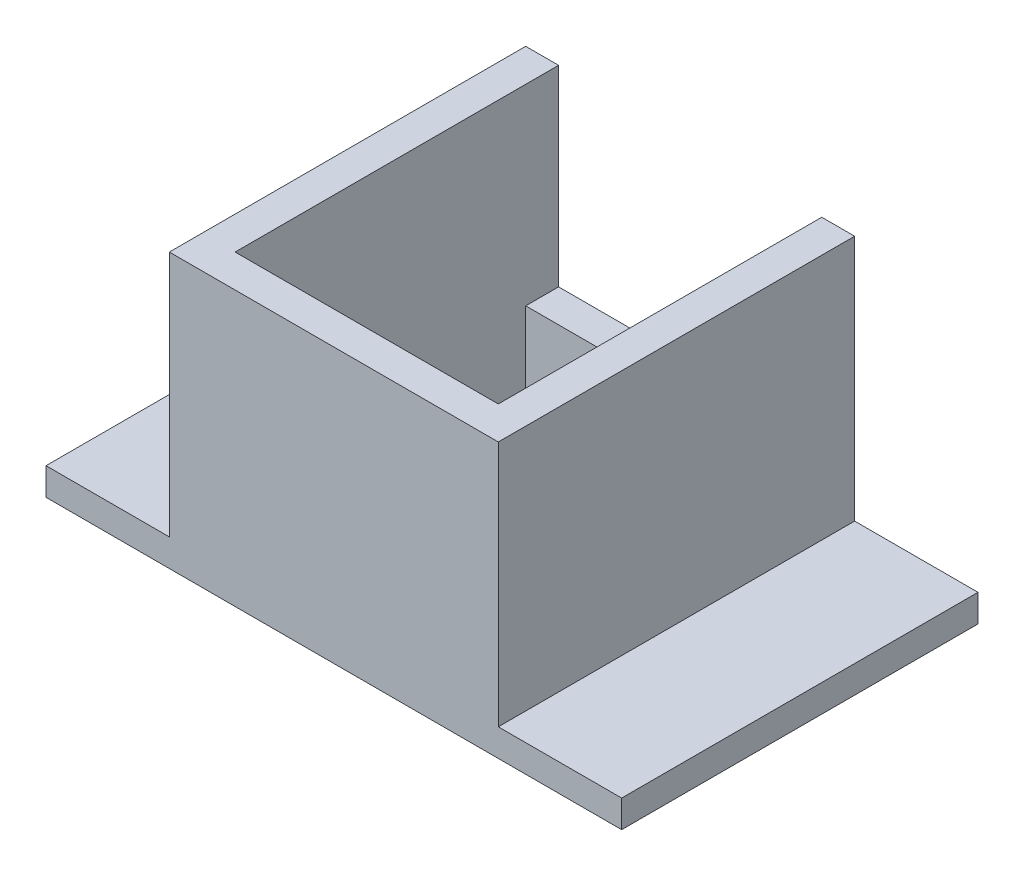
from build123d import *

# Parameters (mm, degrees)
SKETCH1_W           = 12
SKETCH1_H           = 13
SKETCH1_W_2         = 9.6
SKETCH1_H_2         = 10.6
BOSS_EXTRUDE1_DEPTH = 10
SKETCH2_W           = 4.5
SKETCH2_H           = 13
BOSS_EXTRUDE2_DEPTH = 1
SKETCH3_W           = 9.6
SKETCH3_H           = 1.2
CUT_EXTRUDE1_DEPTH  = 7


with BuildPart() as part:
    # Sketch1 → Boss-Extrude1 (new body)
    with BuildSketch(Plane(origin=(0, 0, 0), x_dir=(1, 0, 0), z_dir=(0, 1, 0))):
        Rectangle(SKETCH1_W, SKETCH1_H)
        Rectangle(SKETCH1_W_2, SKETCH1_H_2, mode=Mode.SUBTRACT)
    extrude(amount=BOSS_EXTRUDE1_DEPTH)

    # Sketch2 → Boss-Extrude2 (add)
    with BuildSketch(Plane(origin=(0, 0, 0), x_dir=(1, 0, 0), z_dir=(0, 1, 0))):
        with Locations((-8.25, 0)):
            Rectangle(SKETCH2_W, SKETCH2_H)
        with Locations((8.25, 0)):
            Rectangle(SKETCH2_W, SKETCH2_H)
    extrude(amount=BOSS_EXTRUDE2_DEPTH)

    # Sketch3 → Cut-Extrude1 (cut)
    with BuildSketch(Plane(origin=(0, 10, 0), x_dir=(1, 0, 0), z_dir=(0, 1, 0))):
        with Locations((0, 5.9)):
            Rectangle(SKETCH3_W, SKETCH3_H)
    extrude(amount=-CUT_EXTRUDE1_DEPTH, mode=Mode.SUBTRACT)


solid = part.part
